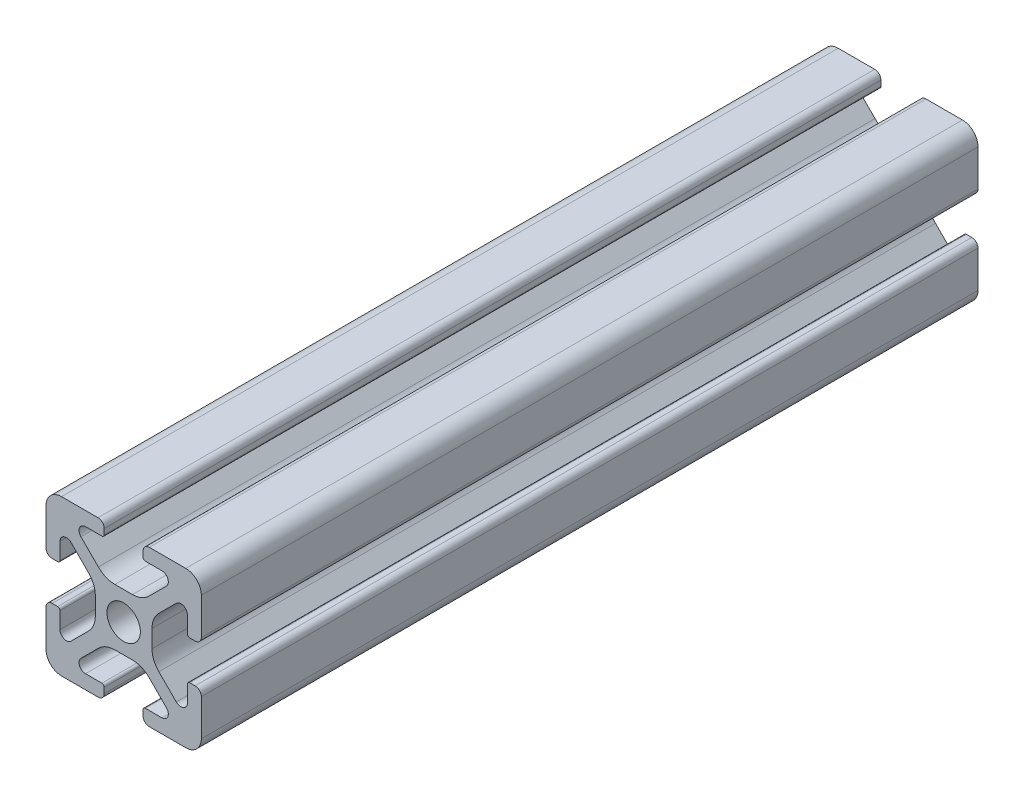
from build123d import *

# Parameters (mm, degrees)
SKETCH1_R           = 2.15
BOSS_EXTRUDE1_DEPTH = 100


with BuildPart() as part:
    # Sketch1 → Boss-Extrude1 (new body)
    with BuildSketch(Plane(origin=(0, 0, 0), x_dir=(-1, 0, 0), z_dir=(0, 0, -1))):
        with BuildLine():
            Line((-12.499999997, 0.800000003), (-12.499999998, 1.500000003))
            ThreePointArc((-12.499999998, 1.500000003), (-12.587867964, 1.712132039), (-12.8, 1.800000005))
            Line((-12.8, 1.800000005), (-14.9175884, 1.800000005))
            ThreePointArc((-14.9175884, 1.800000005), (-15.686636445, 2.313861481), (-15.506192291, 3.221015502))
            Line((-15.506192291, 3.221015502), (-13.255887451, 5.471320342))
            ThreePointArc((-13.255887451, 5.471320342), (-12.282617405, 6.121638595), (-11.134567109, 6.349999998))
            Line((-11.134567109, 6.349999998), (-8.865432906, 6.349999998))
            ThreePointArc((-8.865432906, 6.349999998), (-7.717382611, 6.121638596), (-6.744112565, 5.471320342))
            Line((-6.744112565, 5.471320342), (-4.493807727, 3.221015504))
            ThreePointArc((-4.493807727, 3.221015504), (-4.313363573, 2.313861481), (-5.082411619, 1.800000005))
            Line((-5.082411619, 1.800000005), (-7.20000001, 1.800000005))
            ThreePointArc((-7.20000001, 1.800000005), (-7.412132045, 1.71213204), (-7.50000001, 1.500000005))
            Line((-7.50000001, 1.500000005), (-7.50000001, 0.8))
            ThreePointArc((-7.50000001, 0.8), (-7.265685435, 0.234314575), (-6.70000001, 0))
            Line((-6.70000001, 0), (-2, 0))
            ThreePointArc((-2, 0), (-0.585786438, 0.585786438), (0, 2))
            Line((0, 2), (0, 6.699999998))
            ThreePointArc((0, 6.699999998), (-0.234314576, 7.265685424), (-0.800000003, 7.5))
            Line((-0.800000003, 7.5), (-1.500000007, 7.5))
            ThreePointArc((-1.500000007, 7.5), (-1.712132044, 7.412132033), (-1.80000001, 7.199999997))
            Line((-1.80000001, 7.199999997), (-1.80000001, 5.082411604))
            ThreePointArc((-1.80000001, 5.082411604), (-2.313861485, 4.313363559), (-3.221015507, 4.493807713))
            Line((-3.221015507, 4.493807713), (-5.471320347, 6.744112553))
            ThreePointArc((-5.471320347, 6.744112553), (-6.1216386, 7.717382599), (-6.350000003, 8.865432896))
            Line((-6.350000003, 8.865432896), (-6.350000003, 11.134567105))
            ThreePointArc((-6.350000003, 11.134567105), (-6.121638601, 12.2826174), (-5.471320347, 13.255887446))
            Line((-5.471320347, 13.255887446), (-3.221015511, 15.506192282))
            ThreePointArc((-3.221015511, 15.506192282), (-2.313861487, 15.686636436), (-1.80000001, 14.917588389))
            Line((-1.80000001, 14.917588389), (-1.80000001, 12.799999998))
            ThreePointArc((-1.80000001, 12.799999998), (-1.712132045, 12.587867963), (-1.50000001, 12.499999997))
            Line((-1.50000001, 12.499999997), (-0.8, 12.499999997))
            ThreePointArc((-0.8, 12.499999997), (-0.234314575, 12.734314573), (0, 13.299999998))
            Line((0, 13.299999998), (0, 18))
            ThreePointArc((0, 18), (-0.585786438, 19.414213562), (-2, 20))
            Line((-2, 20), (-6.700000008, 20))
            ThreePointArc((-6.700000008, 20), (-7.265685435, 19.765685424), (-7.50000001, 19.199999998))
            Line((-7.50000001, 19.199999998), (-7.50000001, 18.500000005))
            ThreePointArc((-7.50000001, 18.500000005), (-7.412132044, 18.287867969), (-7.200000008, 18.200000003))
            Line((-7.200000008, 18.200000003), (-5.082411595, 18.200000003))
            ThreePointArc((-5.082411595, 18.200000003), (-4.313363547, 17.686138525), (-4.493807702, 16.7789845))
            Line((-4.493807702, 16.7789845), (-6.744112543, 14.528679659))
            ThreePointArc((-6.744112543, 14.528679659), (-7.717382589, 13.878361405), (-8.865432885, 13.650000003))
            Line((-8.865432885, 13.650000003), (-11.134567111, 13.650000003))
            ThreePointArc((-11.134567111, 13.650000003), (-12.282617406, 13.878361405), (-13.255887452, 14.528679658))
            Line((-13.255887452, 14.528679658), (-15.506192292, 16.778984498))
            ThreePointArc((-15.506192292, 16.778984498), (-15.686636447, 17.686138525), (-14.917588397, 18.200000002))
            Line((-14.917588397, 18.200000002), (-12.799999998, 18.200000003))
            ThreePointArc((-12.799999998, 18.200000003), (-12.587867963, 18.287867968), (-12.499999997, 18.500000002))
            Line((-12.499999997, 18.500000002), (-12.499999997, 19.2))
            ThreePointArc((-12.499999997, 19.2), (-12.734314573, 19.765685425), (-13.299999998, 20))
            Line((-13.299999998, 20), (-18, 20))
            ThreePointArc((-18, 20), (-19.414213562, 19.414213562), (-20, 18))
            Line((-20, 18), (-20, 13.3))
            ThreePointArc((-20, 13.3), (-19.765685424, 12.734314573), (-19.199999998, 12.499999997))
            Line((-19.199999998, 12.499999997), (-18.500000003, 12.499999997))
            ThreePointArc((-18.500000003, 12.499999997), (-18.287867967, 12.587867964), (-18.2, 12.8))
            Line((-18.2, 12.8), (-18.2, 14.91758839))
            ThreePointArc((-18.2, 14.91758839), (-17.686138525, 15.686636435), (-16.778984504, 15.506192281))
            Line((-16.778984504, 15.506192281), (-14.528679657, 13.255887434))
            ThreePointArc((-14.528679657, 13.255887434), (-13.878361403, 12.282617388), (-13.65, 11.134567091))
            Line((-13.65, 11.134567091), (-13.65, 8.865432887))
            ThreePointArc((-13.65, 8.865432887), (-13.878361403, 7.717382591), (-14.528679656, 6.744112546))
            Line((-14.528679656, 6.744112546), (-16.778984496, 4.493807706))
            ThreePointArc((-16.778984496, 4.493807706), (-17.686138522, 4.313363551), (-18.2, 5.0824116))
            Line((-18.2, 5.0824116), (-18.2, 7.2))
            ThreePointArc((-18.2, 7.2), (-18.287867966, 7.412132034), (-18.5, 7.5))
            Line((-18.5, 7.5), (-19.2, 7.5))
            ThreePointArc((-19.2, 7.5), (-19.765685425, 7.265685425), (-20, 6.7))
            Line((-20, 6.7), (-20, 2))
            ThreePointArc((-20, 2), (-19.414213562, 0.585786438), (-18, 0))
            Line((-18, 0), (-13.3, 0))
            ThreePointArc((-13.3, 0), (-12.734314573, 0.234314576), (-12.499999997, 0.800000003))
        make_face()
        with Locations((-10, 10)):
            Circle(SKETCH1_R, mode=Mode.SUBTRACT)
    extrude(amount=-BOSS_EXTRUDE1_DEPTH)


solid = part.part
